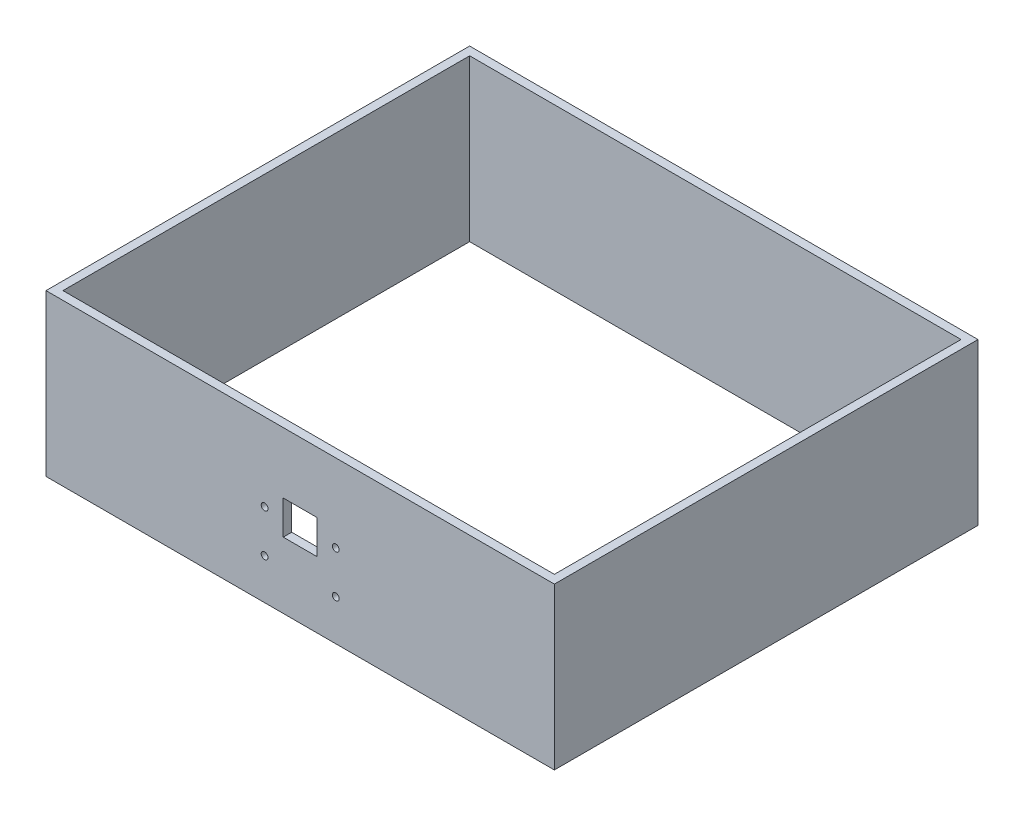
from build123d import *

# Parameters (mm, degrees)
SKETCH1_W           = 150
SKETCH1_H           = 125
BOSS_EXTRUDE1_DEPTH = 47.5
SHELL1_T            = -2.5
SKETCH2_R           = 1
SKETCH2_W           = 10
SKETCH2_H           = 10
CUT_EXTRUDE1_DEPTH  = 2.5


with BuildPart() as part:
    # Sketch1 → Boss-Extrude1 (new body)
    with BuildSketch(Plane(origin=(0, 0, 0), x_dir=(1, 0, 0), z_dir=(0, 1, 0))):
        Rectangle(SKETCH1_W, SKETCH1_H)
    extrude(amount=BOSS_EXTRUDE1_DEPTH)

    # Shell1
    shell1_openings = [part.faces().sort_by_distance(p)[0] for p in [
        (0, 47.5, 0),
        (0, 0, 0),
    ]]
    offset(amount=SHELL1_T, openings=shell1_openings, kind=Kind.INTERSECTION)

    # Sketch2 → Cut-Extrude1 (cut)
    with BuildSketch(Plane.XY.offset(62.5)):
        with Locations((-10.5, 12)):
            Circle(SKETCH2_R)
        with Locations((-10.5, 24.5)):
            Circle(SKETCH2_R)
        with Locations((10.5, 12)):
            Circle(SKETCH2_R)
        with Locations((10.5, 24.5)):
            Circle(SKETCH2_R)
        with Locations((0, 24.5)):
            Rectangle(SKETCH2_W, SKETCH2_H)
    extrude(amount=-CUT_EXTRUDE1_DEPTH, mode=Mode.SUBTRACT)


solid = part.part
